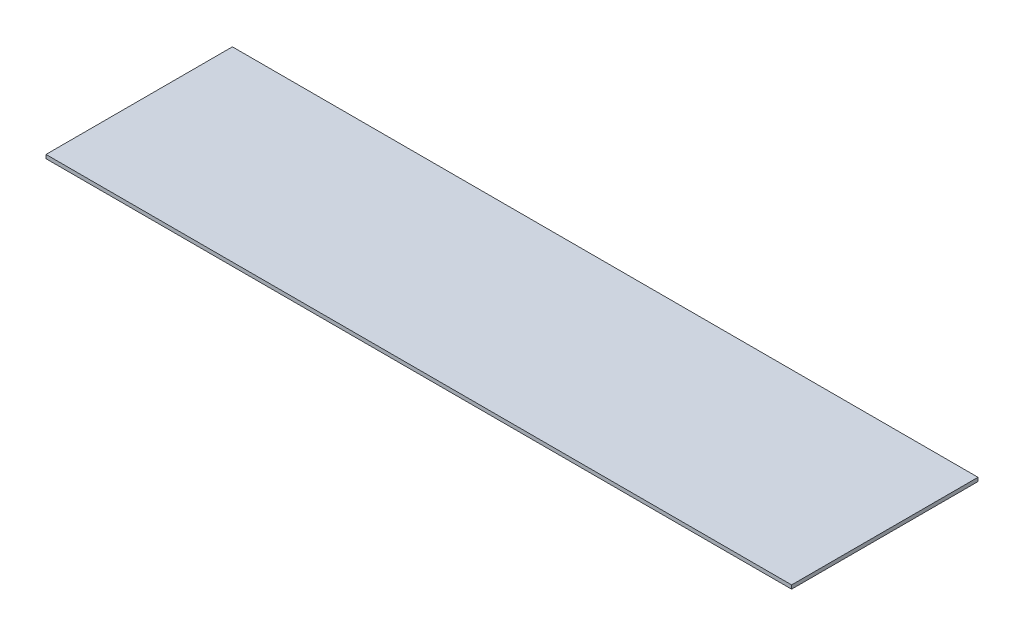
from build123d import *

# Parameters (mm, degrees)
SKETCH1_W           = 2000
SKETCH1_H           = 500
BOSS_EXTRUDE1_DEPTH = 5


with BuildPart() as part:
    # Sketch1 → Boss-Extrude1 (new body, symmetric)
    with BuildSketch(Plane(origin=(0, 0, 0), x_dir=(1, 0, 0), z_dir=(0, 1, 0))):
        Rectangle(SKETCH1_W, SKETCH1_H)
    extrude(amount=BOSS_EXTRUDE1_DEPTH, both=True)


solid = part.part
